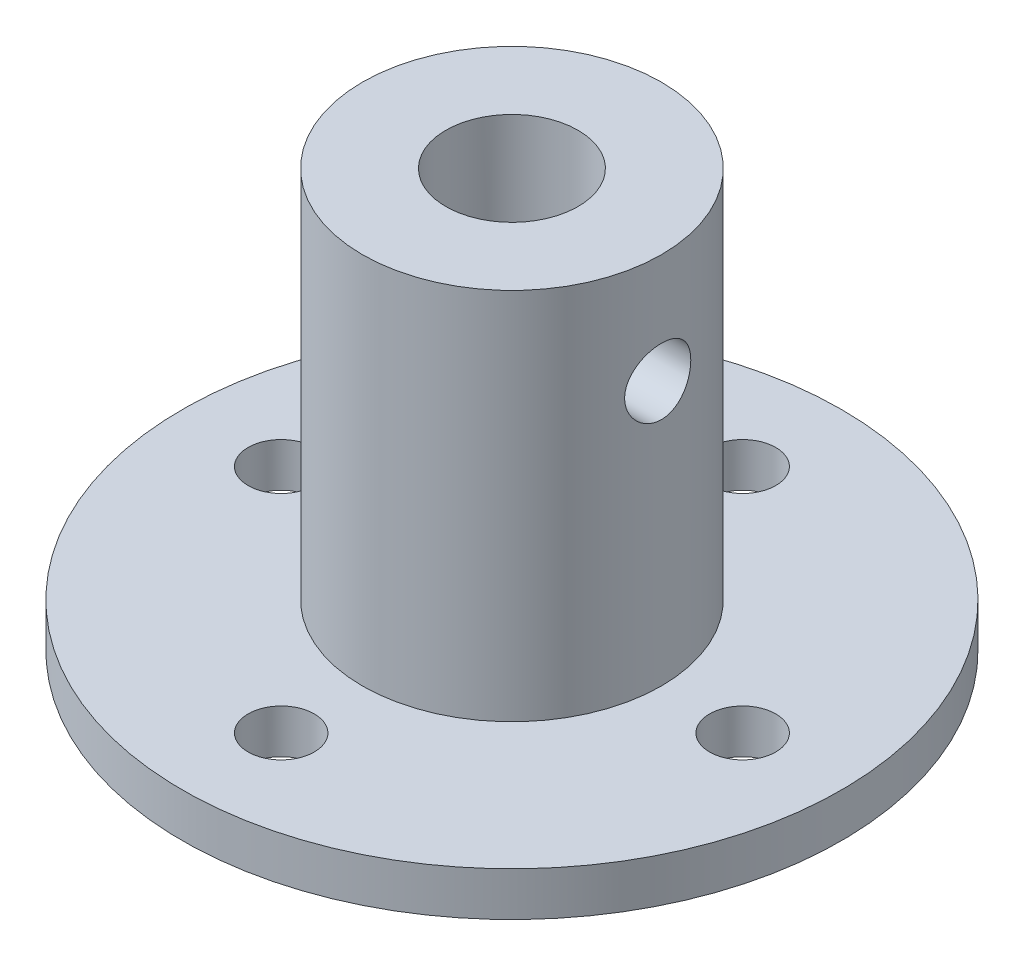
from build123d import *

# Parameters (mm, degrees)
SKETCH1_5_R             = 1.1938
CUT_EXTRUDE1_DEPTH      = 12.8999
CUT_EXTRUDE1_DEPTH_BACK = 12.8999
SKETCH2_R               = 1.1938
CUT_EXTRUDE2_DEPTH      = 17.6624001


with BuildPart() as part:
    # Sketch1 → Revolve1 (revolve)
    with BuildSketch(Plane(origin=(0, 0, 0), x_dir=(0, 0, -1), z_dir=(1, 0, 0))):
        Polygon((3.9243, 0), (2.3876, 0), (2.3876, 16.6624), (5.3975, 16.6624), (5.3975, 3.175), (11.8999, 3.175), (11.8999, 1.5875), (3.9243, 1.5875), align=None)
    revolve(axis=Axis((0, 0, 0), (0, 1, 0)))

    # Sketch1_5 → Cut-Extrude1 (cut, two sides)
    with BuildSketch(Plane(origin=(0, 0, 0), x_dir=(0, 0, -1), z_dir=(1, 0, 0))) as cut_extrude1_sk:
        with Locations((0, 12.7)):
            Circle(SKETCH1_5_R)
    extrude(amount=CUT_EXTRUDE1_DEPTH, mode=Mode.SUBTRACT)
    extrude(cut_extrude1_sk.sketch, amount=-CUT_EXTRUDE1_DEPTH_BACK, mode=Mode.SUBTRACT)

    # Sketch2 → Cut-Extrude2 (cut, through all)
    with BuildSketch(Plane(origin=(0, 0, 0), x_dir=(1, 0, 0), z_dir=(0, 1, 0))):
        with Locations(Location((-8.3312, 0, 0), (0, 0, 90))):  # turned: the seam where the file's is
            Circle(SKETCH2_R)
        with Locations(Location((0, 8.3312, 0), (0, 0, 90))):  # turned: the seam where the file's is
            Circle(SKETCH2_R)
        with Locations(Location((0, -8.3312, 0), (0, 0, 90))):  # turned: the seam where the file's is
            Circle(SKETCH2_R)
        with Locations(Location((8.3312, 0, 0), (0, 0, 90))):  # turned: the seam where the file's is
            Circle(SKETCH2_R)
    extrude(amount=CUT_EXTRUDE2_DEPTH, mode=Mode.SUBTRACT)


solid = part.part
